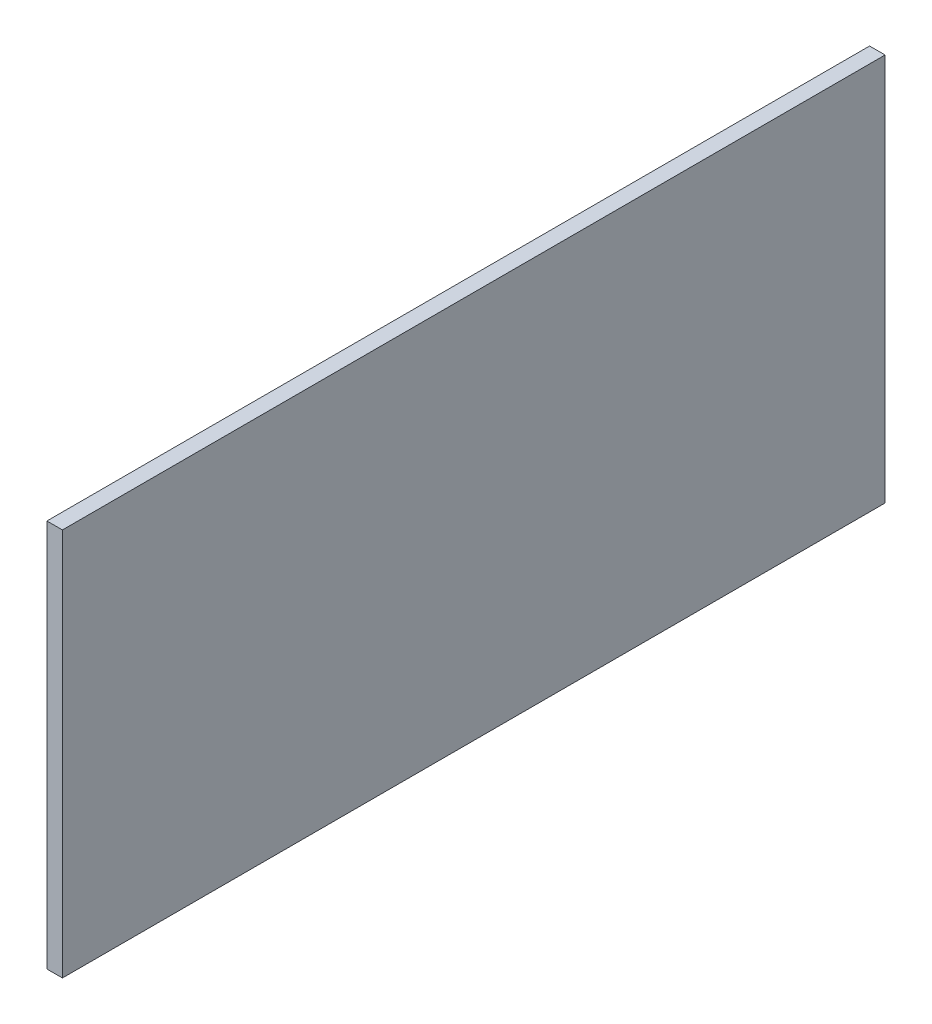
from build123d import *

# Parameters (mm, degrees)
CROQUIS1_W              = 159.01
CROQUIS1_H              = 75
SALIENTE_EXTRUIR1_DEPTH = 3


with BuildPart() as part:
    # Croquis1 → Saliente-Extruir1 (new body)
    with BuildSketch(Plane(origin=(0, 0, 0), x_dir=(0, 0, -1), z_dir=(1, 0, 0))):
        Rectangle(CROQUIS1_W, CROQUIS1_H)
    extrude(amount=SALIENTE_EXTRUIR1_DEPTH)


solid = part.part
